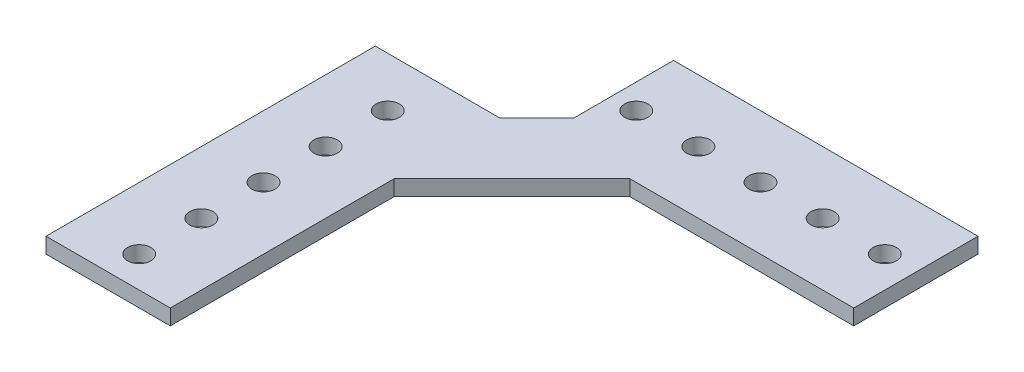
from build123d import *

# Parameters (mm, degrees)
SKETCH1_R           = 2.38125
BOSS_EXTRUDE1_DEPTH = 3.175


with BuildPart() as part:
    # Sketch1 → Boss-Extrude1 (new body)
    with BuildSketch(Plane(origin=(0, 0, 0), x_dir=(1, 0, 0), z_dir=(0, 1, 0))):
        Polygon((0, 67.31), (0, 0), (25.4, 0), (25.4, 45.757385309), (49.492614691, 69.85), (95.25, 69.85), (95.25, 95.25), (33.02, 95.25), (33.02, 74.93), (25.4, 67.31), align=None)
        with Locations((12.7, 19.05)):
            Circle(SKETCH1_R, mode=Mode.SUBTRACT)
        with Locations((12.7, 31.75)):
            Circle(SKETCH1_R, mode=Mode.SUBTRACT)
        with Locations((12.7, 44.45)):
            Circle(SKETCH1_R, mode=Mode.SUBTRACT)
        with Locations((12.7, 57.15)):
            Circle(SKETCH1_R, mode=Mode.SUBTRACT)
        with Locations((38.1, 82.55)):
            Circle(SKETCH1_R, mode=Mode.SUBTRACT)
        with Locations((50.8, 82.55)):
            Circle(SKETCH1_R, mode=Mode.SUBTRACT)
        with Locations((63.5, 82.55)):
            Circle(SKETCH1_R, mode=Mode.SUBTRACT)
        with Locations((76.2, 82.55)):
            Circle(SKETCH1_R, mode=Mode.SUBTRACT)
        with Locations((88.9, 82.55)):
            Circle(SKETCH1_R, mode=Mode.SUBTRACT)
        with Locations((12.7, 6.35)):
            Circle(SKETCH1_R, mode=Mode.SUBTRACT)
    extrude(amount=BOSS_EXTRUDE1_DEPTH)


solid = part.part
